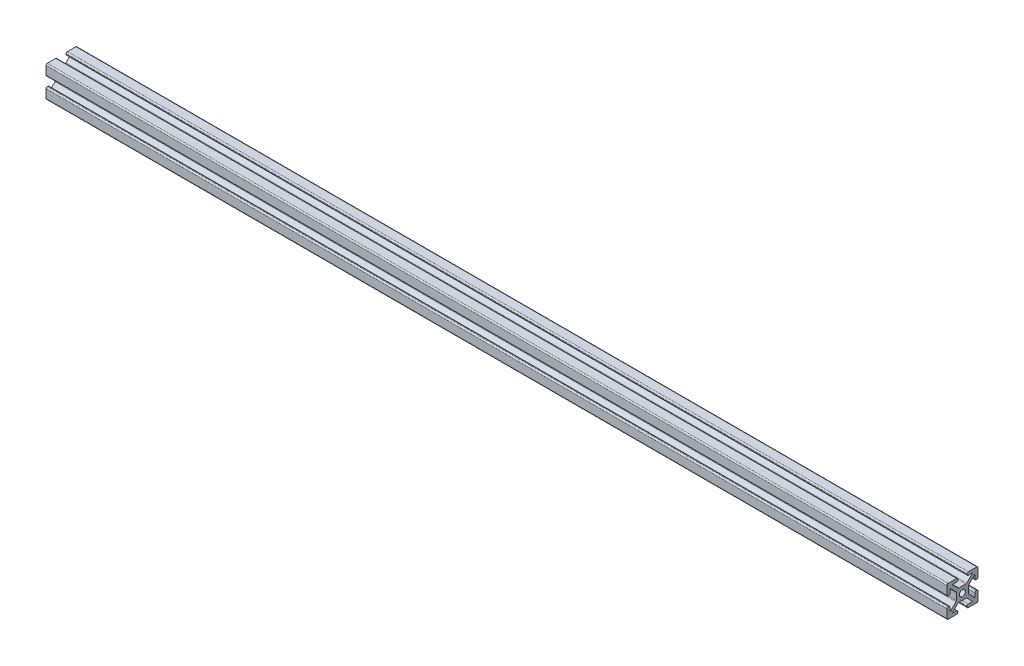
from build123d import *

# Parameters (mm, degrees)
SKETCH1_R           = 2
PROFILE_4X4_1_DEPTH = 580


with BuildPart() as part:
    # Sketch1 → Profile 4X4(1) (new body)
    with BuildSketch(Plane.YZ.offset(-256.36)):
        with BuildLine():
            Line((-3, 9.2), (-3, 8.8))
            ThreePointArc((-3, 8.8), (-3.234314575, 8.234314575), (-3.8, 8))
            Line((-3.8, 8), (-6.585786438, 8))
            Line((-6.585786438, 8), (-2.820101013, 4.234314575))
            ThreePointArc((-2.820101013, 4.234314575), (-2.560562334, 4.060896374), (-2.254415588, 4))
            Line((-2.254415588, 4), (2.254415588, 4))
            ThreePointArc((2.254415588, 4), (2.560562334, 4.060896374), (2.820101013, 4.234314575))
            Line((2.820101013, 4.234314575), (6.585786438, 8))
            Line((6.585786438, 8), (3.8, 8))
            ThreePointArc((3.8, 8), (3.234314575, 8.234314575), (3, 8.8))
            Line((3, 8.8), (3, 9.2))
            ThreePointArc((3, 9.2), (3.234314575, 9.765685425), (3.8, 10))
            Line((3.8, 10), (9.2, 10))
            ThreePointArc((9.2, 10), (9.765685425, 9.765685425), (10, 9.2))
            Line((10, 9.2), (10, 3.8))
            ThreePointArc((10, 3.8), (9.765685425, 3.234314575), (9.2, 3))
            Line((9.2, 3), (8.8, 3))
            ThreePointArc((8.8, 3), (8.234314575, 3.234314575), (8, 3.8))
            Line((8, 3.8), (8, 6.585786438))
            Line((8, 6.585786438), (4.234314575, 2.820101013))
            ThreePointArc((4.234314575, 2.820101013), (4.060896374, 2.560562334), (4, 2.254415588))
            Line((4, 2.254415588), (4, -2.254415588))
            ThreePointArc((4, -2.254415588), (4.060896374, -2.560562334), (4.234314575, -2.820101013))
            Line((4.234314575, -2.820101013), (8, -6.585786438))
            Line((8, -6.585786438), (8, -3.8))
            ThreePointArc((8, -3.8), (8.234314575, -3.234314575), (8.8, -3))
            Line((8.8, -3), (9.2, -3))
            ThreePointArc((9.2, -3), (9.765685425, -3.234314575), (10, -3.8))
            Line((10, -3.8), (10, -9.2))
            ThreePointArc((10, -9.2), (9.765685425, -9.765685425), (9.2, -10))
            Line((9.2, -10), (3.8, -10))
            ThreePointArc((3.8, -10), (3.234314575, -9.765685425), (3, -9.2))
            Line((3, -9.2), (3, -8.8))
            ThreePointArc((3, -8.8), (3.234314575, -8.234314575), (3.8, -8))
            Line((3.8, -8), (6.585786438, -8))
            Line((6.585786438, -8), (2.820101013, -4.234314575))
            ThreePointArc((2.820101013, -4.234314575), (2.560562334, -4.060896374), (2.254415588, -4))
            Line((2.254415588, -4), (-2.254415588, -4))
            ThreePointArc((-2.254415588, -4), (-2.560562334, -4.060896374), (-2.820101013, -4.234314575))
            Line((-2.820101013, -4.234314575), (-6.585786438, -8))
            Line((-6.585786438, -8), (-3.8, -8))
            ThreePointArc((-3.8, -8), (-3.234314575, -8.234314575), (-3, -8.8))
            Line((-3, -8.8), (-3, -9.2))
            ThreePointArc((-3, -9.2), (-3.234314575, -9.765685425), (-3.8, -10))
            Line((-3.8, -10), (-9.2, -10))
            ThreePointArc((-9.2, -10), (-9.765685425, -9.765685425), (-10, -9.2))
            Line((-10, -9.2), (-10, -3.8))
            ThreePointArc((-10, -3.8), (-9.765685425, -3.234314575), (-9.2, -3))
            Line((-9.2, -3), (-8.8, -3))
            ThreePointArc((-8.8, -3), (-8.234314575, -3.234314575), (-8, -3.8))
            Line((-8, -3.8), (-8, -6.585786438))
            Line((-8, -6.585786438), (-4.234314575, -2.820101013))
            ThreePointArc((-4.234314575, -2.820101013), (-4.060896374, -2.560562334), (-4, -2.254415588))
            Line((-4, -2.254415588), (-4, 2.254415588))
            ThreePointArc((-4, 2.254415588), (-4.060896374, 2.560562334), (-4.234314575, 2.820101013))
            Line((-4.234314575, 2.820101013), (-8, 6.585786438))
            Line((-8, 6.585786438), (-8, 3.8))
            ThreePointArc((-8, 3.8), (-8.234314575, 3.234314575), (-8.8, 3))
            Line((-8.8, 3), (-9.2, 3))
            ThreePointArc((-9.2, 3), (-9.765685425, 3.234314575), (-10, 3.8))
            Line((-10, 3.8), (-10, 9.2))
            ThreePointArc((-10, 9.2), (-9.765685425, 9.765685425), (-9.2, 10))
            Line((-9.2, 10), (-3.8, 10))
            ThreePointArc((-3.8, 10), (-3.234314575, 9.765685425), (-3, 9.2))
        make_face()
        Circle(SKETCH1_R, mode=Mode.SUBTRACT)
    extrude(amount=PROFILE_4X4_1_DEPTH)


solid = part.part
